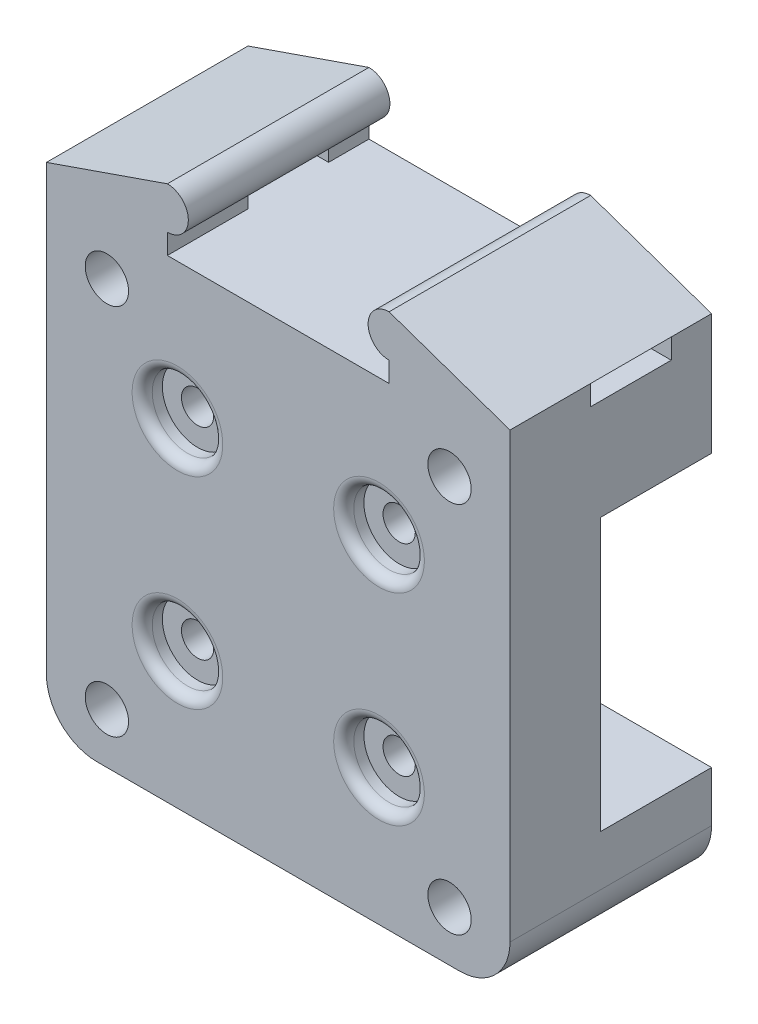
from build123d import *

# Parameters (mm, degrees)
SKETCH1_W               = 46
SKETCH1_H               = 47
BOSS_EXTRUDE1_DEPTH     = 9
SKETCH2_R               = 1.6
CUT_EXTRUDE1_DEPTH      = 10
SKETCH3_W               = 46
SKETCH3_H               = 10
BOSS_EXTRUDE2_DEPTH     = 11
SKETCH4_R               = 2.15
CUT_EXTRUDE2_DEPTH      = 10
CUT_EXTRUDE2_DEPTH_BACK = 12
BOSS_EXTRUDE5_DEPTH     = 20
SKETCH8_W               = 8
SKETCH8_H               = 2
CUT_EXTRUDE3_DEPTH      = 24
CUT_EXTRUDE3_DEPTH_BACK = 24
SKETCH9_R               = 3.5
CUT_EXTRUDE4_DEPTH      = 2
FILLET1_R               = 1
FILLET2_R               = 5
SKETCH10_R              = 3.2
CUT_EXTRUDE5_DEPTH      = 13


with BuildPart() as part:
    # Sketch1 → Boss-Extrude1 (new body)
    with BuildSketch(Plane.XY):
        Rectangle(SKETCH1_W, SKETCH1_H)
    extrude(amount=BOSS_EXTRUDE1_DEPTH)

    # Sketch2 → Cut-Extrude1 (cut)
    with BuildSketch(Plane.XY.offset(9)):
        with Locations((-10, 10)):
            Circle(SKETCH2_R)
        with Locations((10, 10)):
            Circle(SKETCH2_R)
        with Locations((-10, -10)):
            Circle(SKETCH2_R)
        with Locations((10, -10)):
            Circle(SKETCH2_R)
    extrude(amount=-CUT_EXTRUDE1_DEPTH, mode=Mode.SUBTRACT)

    # Sketch3 → Boss-Extrude2 (add)
    with BuildSketch(Plane.XY):
        with Locations((0, 18.5)):
            Rectangle(SKETCH3_W, SKETCH3_H)
        with Locations((0, -18.5)):
            Rectangle(SKETCH3_W, SKETCH3_H)
    extrude(amount=-BOSS_EXTRUDE2_DEPTH)

    # Sketch4 → Cut-Extrude2 (cut, two sides)
    with BuildSketch(Plane.XY) as cut_extrude2_sk:
        with Locations((-17, 18.5)):
            Circle(SKETCH4_R)
        with Locations((17, 18.5)):
            Circle(SKETCH4_R)
        with Locations((-17, -18.5)):
            Circle(SKETCH4_R)
        with Locations((17, -18.5)):
            Circle(SKETCH4_R)
    extrude(amount=CUT_EXTRUDE2_DEPTH, mode=Mode.SUBTRACT)
    extrude(cut_extrude2_sk.sketch, amount=-CUT_EXTRUDE2_DEPTH_BACK, mode=Mode.SUBTRACT)

    # Sketch7 → Boss-Extrude5 (add)
    with BuildSketch(Plane(origin=(0, 0, -11), x_dir=(-1, 0, 0), z_dir=(0, 0, -1))):
        with BuildLine():
            Line((-23, 23.5), (-11, 23.5))
            Line((-11, 23.5), (-11, 25.5))
            ThreePointArc((-11, 25.5), (-8.920338159, 27.579661841), (-11, 29.659323681))
            Line((-11, 29.659323681), (-23, 25.5))
            Line((-23, 25.5), (-23, 23.5))
        make_face()
        with BuildLine():
            Line((23, 23.5), (11, 23.5))
            Line((11, 23.5), (11, 25.5))
            ThreePointArc((11, 25.5), (8.920338159, 27.579661841), (11, 29.659323681))
            Line((11, 29.659323681), (23, 25.5))
            Line((23, 25.5), (23, 23.5))
        make_face()
    extrude(amount=-BOSS_EXTRUDE5_DEPTH)

    # Sketch8 → Cut-Extrude3 (cut, two sides)
    with BuildSketch(Plane(origin=(0, 0, 0), x_dir=(0, 0, -1), z_dir=(1, 0, 0))) as cut_extrude3_sk:
        with Locations((3, 24.5)):
            Rectangle(SKETCH8_W, SKETCH8_H)
    extrude(amount=CUT_EXTRUDE3_DEPTH, mode=Mode.SUBTRACT)
    extrude(cut_extrude3_sk.sketch, amount=-CUT_EXTRUDE3_DEPTH_BACK, mode=Mode.SUBTRACT)

    # Sketch9 → Cut-Extrude4 (cut)
    with BuildSketch(Plane.XY.offset(9)):
        with Locations((-10, 10)):
            Circle(SKETCH9_R)
        with Locations((10, 10)):
            Circle(SKETCH9_R)
        with Locations((10, -10)):
            Circle(SKETCH9_R)
        with Locations((-10, -10)):
            Circle(SKETCH9_R)
    extrude(amount=-CUT_EXTRUDE4_DEPTH, mode=Mode.SUBTRACT)

    # Fillet1
    fillet1_edges = [part.edges().sort_by_distance(p)[0] for p in [
        (-13.5, -10, 9),
        (6.5, -10, 9),
        (6.5, 10, 9),
        (-13.5, 10, 9),
    ]]
    fillet(fillet1_edges, radius=FILLET1_R)

    # Fillet2
    fillet2_edges = [part.edges().sort_by_distance(p)[0] for p in [
        (23, -23.5, -1),
        (-23, -23.5, -1),
    ]]
    fillet(fillet2_edges, radius=FILLET2_R)

    # Sketch10 → Cut-Extrude5 (cut)
    with BuildSketch(Plane(origin=(0, 0, -11), x_dir=(-1, 0, 0), z_dir=(0, 0, -1))):
        with Locations((-17, -18.5)):
            Circle(SKETCH10_R)
        with Locations((17, -18.5)):
            Circle(SKETCH10_R)
        with Locations((17, 18.5)):
            Circle(SKETCH10_R)
        with Locations((-17, 18.5)):
            Circle(SKETCH10_R)
    extrude(amount=-CUT_EXTRUDE5_DEPTH, mode=Mode.SUBTRACT)


solid = part.part
